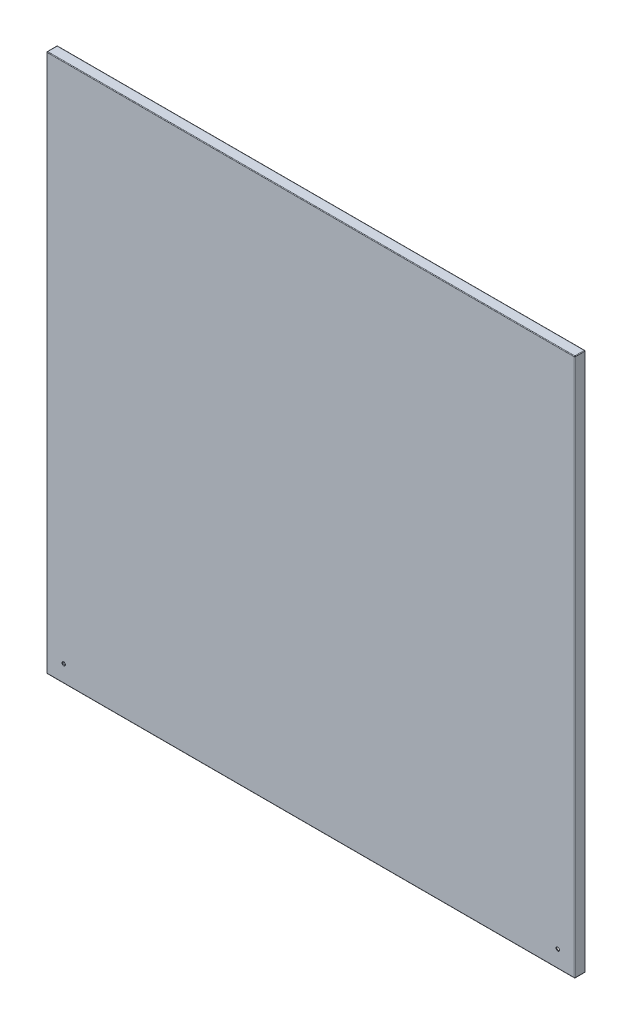
from build123d import *

# Parameters (mm, degrees)
SKETCH_1_W          = 900
SKETCH_1_H          = 918
EXTRUDE_1_DEPTH     = 1.5
SKETCH_2_W          = 900
SKETCH_2_H          = 918
SKETCH_2_W_2        = 897
SKETCH_2_H_2        = 915
EXTRUDE_2_DEPTH     = 15
SKETCH_3_W          = 900
SKETCH_3_H          = 918
SKETCH_3_W_2        = 870
SKETCH_3_H_2        = 898
EXTRUDE_3_DEPTH     = 1.5
SKETCH_6_R          = 3
CUT_EXTRUDE_1_DEPTH = 19
FILLET_1_R          = 1


with BuildPart() as part:
    # 草图1 → 凸台-拉伸1 (new body)
    with BuildSketch(Plane.XY):
        Rectangle(SKETCH_1_W, SKETCH_1_H)
    extrude(amount=EXTRUDE_1_DEPTH)

    # 草图2 → 凸台-拉伸2 (add)
    with BuildSketch(Plane(origin=(0, 0, 0), x_dir=(-1, 0, 0), z_dir=(0, 0, -1))):
        Rectangle(SKETCH_2_W, SKETCH_2_H)
        Rectangle(SKETCH_2_W_2, SKETCH_2_H_2, mode=Mode.SUBTRACT)
    extrude(amount=EXTRUDE_2_DEPTH)

    # 草图3 → 凸台-拉伸3 (add)
    with BuildSketch(Plane(origin=(0, 0, -15), x_dir=(-1, 0, 0), z_dir=(0, 0, -1))):
        Rectangle(SKETCH_3_W, SKETCH_3_H)
        Rectangle(SKETCH_3_W_2, SKETCH_3_H_2, mode=Mode.SUBTRACT)
    extrude(amount=EXTRUDE_3_DEPTH)

    # 草图6 → 切除-拉伸1 (cut, through all)
    with BuildSketch(Plane.XY.offset(1.5)):
        with Locations((-421, -430)):
            Circle(SKETCH_6_R)
        with Locations((421, -430)):
            Circle(SKETCH_6_R)
    extrude(amount=-CUT_EXTRUDE_1_DEPTH, mode=Mode.SUBTRACT)

    # 圆角1
    fillet_1_edges = [part.edges().sort_by_distance(p)[0] for p in [
        (450, 0, 1.5),
        (0, 459, 1.5),
        (-450, 0, -16.5),
        (0, 459, -16.5),
        (450, 0, -16.5),
        (0, -459, -16.5),
        (-450, 0, 1.5),
        (0, -459, 1.5),
        (-450, 459, -7.5),
        (450, 459, -7.5),
        (450, -459, -7.5),
        (-450, -459, -7.5),
    ]]
    fillet(fillet_1_edges, radius=FILLET_1_R)


solid = part.part
